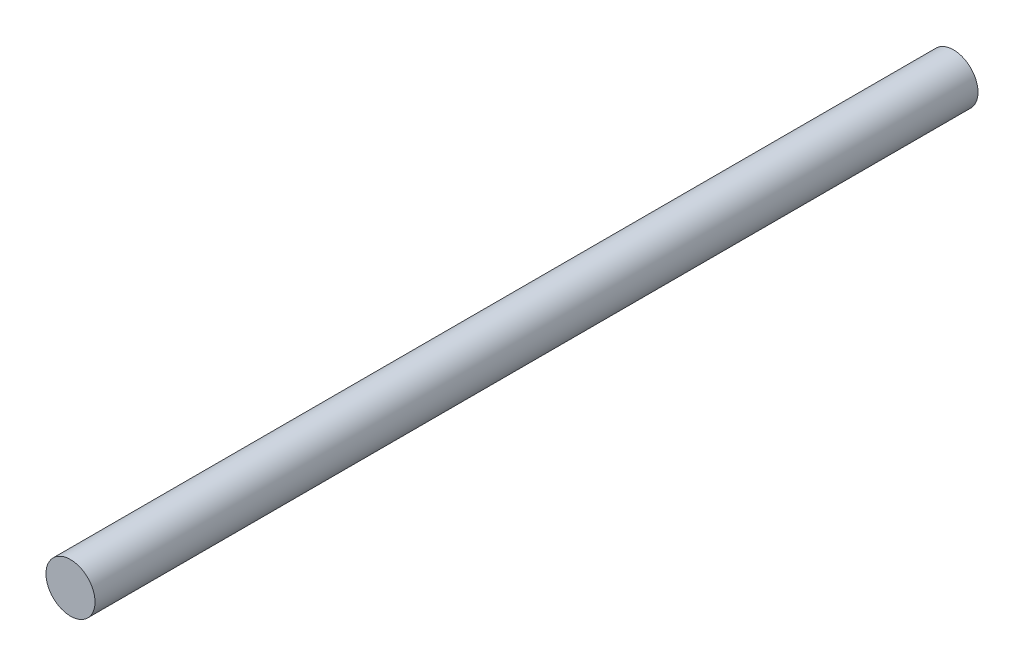
from build123d import *

# Parameters (mm, degrees)
SKETCH_2_R      = 25
EXTRUDE_1_DEPTH = 900


with BuildPart() as part:
    # ｽｹｯﾁ2 → ﾎﾞｽ - 押し出し1 (new body)
    with BuildSketch(Plane.XY):
        Circle(SKETCH_2_R)
    extrude(amount=EXTRUDE_1_DEPTH)


solid = part.part
